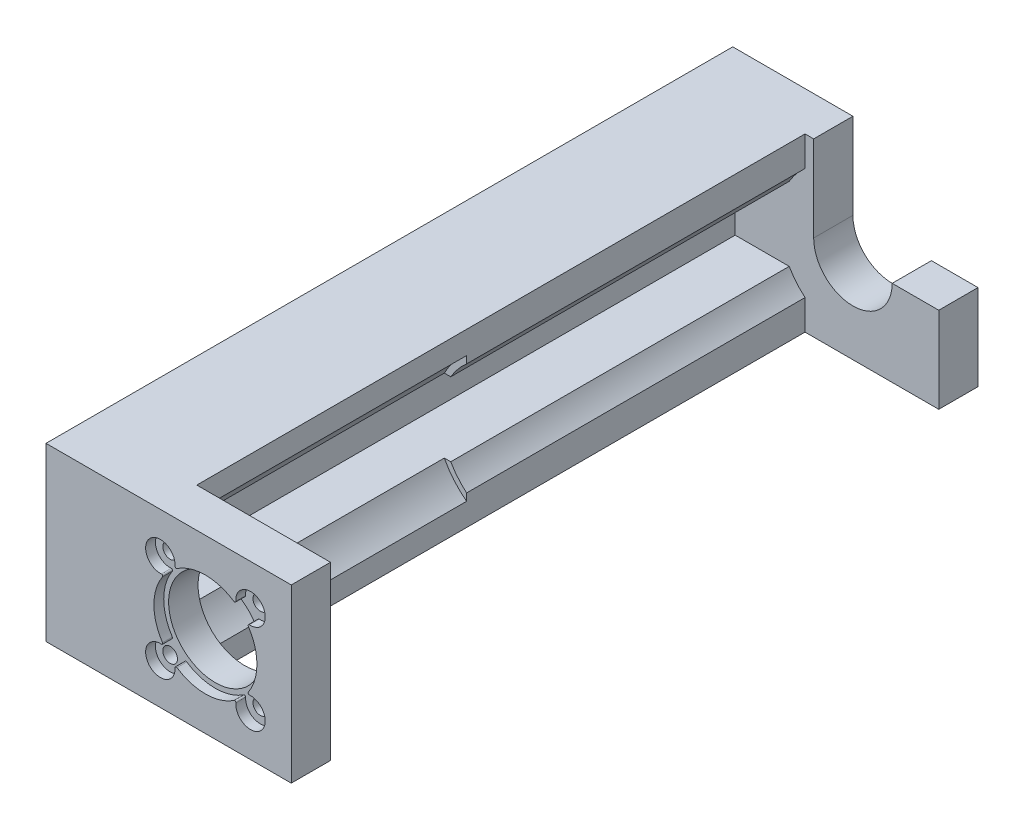
from build123d import *

# Parameters (mm, degrees)
SKETCH1_W            = 50
SKETCH1_H            = 35
SKETCH1_R            = 9.5
SKETCH1_R_2          = 1.5
BOSS_EXTRUDE3_DEPTH  = 6
SKETCH4_W            = 50
SKETCH4_H            = 35
BOSS_EXTRUDE5_DEPTH  = 2
BOSS_EXTRUDE6_DEPTH  = 55
BOSS_EXTRUDE9_DEPTH  = 69
BOSS_EXTRUDE10_DEPTH = 8
SKETCH9_R            = 2
CUT_EXTRUDE1_DEPTH   = 8.5


with BuildPart() as part:
    # Sketch1 → Boss-Extrude3 (new body)
    with BuildSketch(Plane.XY):
        with Locations((25, 17.5)):
            Rectangle(SKETCH1_W, SKETCH1_H)
        with Locations((32.5, 17.5)):
            Circle(SKETCH1_R, mode=Mode.SUBTRACT)
        with Locations((41.692388155, 26.692388155)):
            Circle(SKETCH1_R_2, mode=Mode.SUBTRACT)
        with Locations((41.692388155, 8.307611845)):
            Circle(SKETCH1_R_2, mode=Mode.SUBTRACT)
        with Locations((23.307611845, 8.307611845)):
            Circle(SKETCH1_R_2, mode=Mode.SUBTRACT)
        with Locations((23.307611845, 26.692388155)):
            Circle(SKETCH1_R_2, mode=Mode.SUBTRACT)
    extrude(amount=BOSS_EXTRUDE3_DEPTH)

    # Sketch4 → Boss-Extrude5 (add)
    with BuildSketch(Plane.XY.offset(6)):
        with Locations((25, 17.5)):
            Rectangle(SKETCH4_W, SKETCH4_H)
        with BuildLine():
            ThreePointArc((26.299419693, 26.47083501), (21.186291501, 28.813708499), (23.52916499, 23.700580307))
            ThreePointArc((23.52916499, 23.700580307), (23.763454109, 23.57743344), (23.755822455, 23.312861521))
            ThreePointArc((23.755822455, 23.312861521), (22, 17.5), (23.755822455, 11.687138479))
            ThreePointArc((23.755822455, 11.687138479), (23.763454109, 11.42256656), (23.52916499, 11.299419693))
            ThreePointArc((23.52916499, 11.299419693), (21.186291501, 6.186291501), (26.299419693, 8.52916499))
            ThreePointArc((26.299419693, 8.52916499), (26.42256656, 8.763454109), (26.687138479, 8.755822455))
            ThreePointArc((26.687138479, 8.755822455), (32.5, 7), (38.312861521, 8.755822455))
            ThreePointArc((38.312861521, 8.755822455), (38.57743344, 8.763454109), (38.700580307, 8.52916499))
            ThreePointArc((38.700580307, 8.52916499), (43.813708499, 6.186291501), (41.47083501, 11.299419693))
            ThreePointArc((41.47083501, 11.299419693), (41.236545891, 11.42256656), (41.244177545, 11.687138479))
            ThreePointArc((41.244177545, 11.687138479), (43, 17.5), (41.244177545, 23.312861521))
            ThreePointArc((41.244177545, 23.312861521), (41.236545891, 23.57743344), (41.47083501, 23.700580307))
            ThreePointArc((41.47083501, 23.700580307), (43.813708499, 28.813708499), (38.700580307, 26.47083501))
            ThreePointArc((38.700580307, 26.47083501), (38.57743344, 26.236545891), (38.312861521, 26.244177545))
            ThreePointArc((38.312861521, 26.244177545), (32.5, 28), (26.687138479, 26.244177545))
            ThreePointArc((26.687138479, 26.244177545), (26.42256656, 26.236545891), (26.299419693, 26.47083501))
        make_face(mode=Mode.SUBTRACT)
    extrude(amount=BOSS_EXTRUDE5_DEPTH)

    # Sketch8 → Boss-Extrude6 (add)
    with BuildSketch(Plane(origin=(0, 0, 0), x_dir=(-1, 0, 0), z_dir=(0, 0, -1))):
        with BuildLine():
            Line((-8.5, 35), (-22.740329685, 35))
            Line((-22.740329685, 35), (-22.740329685, 30.367452558))
            ThreePointArc((-22.740329685, 30.367452558), (-20.171344576, 27.9320063), (-18.194683381, 24.99535966))
            Line((-18.194683381, 24.99535966), (-18.194683381, 25))
            Line((-18.194683381, 25), (-8.5, 25))
            Line((-8.5, 25), (-8.5, 10.000000197))
            Line((-8.5, 10.000000197), (-18.197115572, 10.000000197))
            ThreePointArc((-18.197115572, 10.000000197), (-20.17303677, 7.065994176), (-22.740329685, 4.632547442))
            Line((-22.740329685, 4.632547442), (-22.740329685, 0))
            Line((-22.740329685, 0), (-8.5, 0))
            Line((-8.5, 0), (0, 0))
            Line((0, 0), (0, 10.000000197))
            Line((0, 10.000000197), (0, 25))
            Line((0, 25), (0, 35))
            Line((0, 35), (-8.5, 35))
        make_face()
    extrude(amount=BOSS_EXTRUDE6_DEPTH)

    # Sketch13 → Boss-Extrude9 (add)
    with BuildSketch(Plane(origin=(0, 0, -55), x_dir=(-1, 0, 0), z_dir=(0, 0, -1))):
        with BuildLine():
            Line((-8.5, 25), (-8.5, 10))
            Line((-8.5, 10), (-19.509618943, 10))
            ThreePointArc((-19.509618943, 10), (-20.959823947, 7.917498413), (-22.740329685, 6.109265373))
            Line((-22.740329685, 6.109265373), (-22.740329685, 0))
            Line((-22.740329685, 0), (0, 0))
            Line((0, 0), (0, 35))
            Line((0, 35), (-22.740329685, 35))
            Line((-22.740329685, 35), (-22.740329685, 28.890734627))
            ThreePointArc((-22.740329685, 28.890734627), (-20.959823947, 27.082501587), (-19.509618943, 25))
            Line((-19.509618943, 25), (-8.5, 25))
        make_face()
    extrude(amount=BOSS_EXTRUDE9_DEPTH)

    # Sketch14 → Boss-Extrude10 (add)
    with BuildSketch(Plane(origin=(0, 0, -124), x_dir=(-1, 0, 0), z_dir=(0, 0, -1))):
        with BuildLine():
            Line((-24.5, 17.5), (-24.5, 35))
            Line((-24.5, 35), (0, 35))
            Line((0, 35), (0, 0))
            Line((0, 0), (-50, 0))
            Line((-50, 0), (-50, 17.5))
            Line((-50, 17.5), (-40.5, 17.5))
            ThreePointArc((-40.5, 17.5), (-32.5, 9.5), (-24.5, 17.5))
        make_face()
    extrude(amount=BOSS_EXTRUDE10_DEPTH)

    # Sketch9 → Cut-Extrude1 (cut)
    with BuildSketch(Plane.ZY):
        with Locations((-7, 17.5)):
            Circle(SKETCH9_R)
        with Locations((-24, 17.5)):
            Circle(SKETCH9_R)
        with Locations((-41, 17.5)):
            Circle(SKETCH9_R)
        with Locations((-58, 17.5)):
            Circle(SKETCH9_R)
        with Locations((-75, 17.5)):
            Circle(SKETCH9_R)
        with Locations((-92, 17.5)):
            Circle(SKETCH9_R)
        with Locations((-109, 17.5)):
            Circle(SKETCH9_R)
    extrude(amount=-CUT_EXTRUDE1_DEPTH, mode=Mode.SUBTRACT)


solid = part.part
